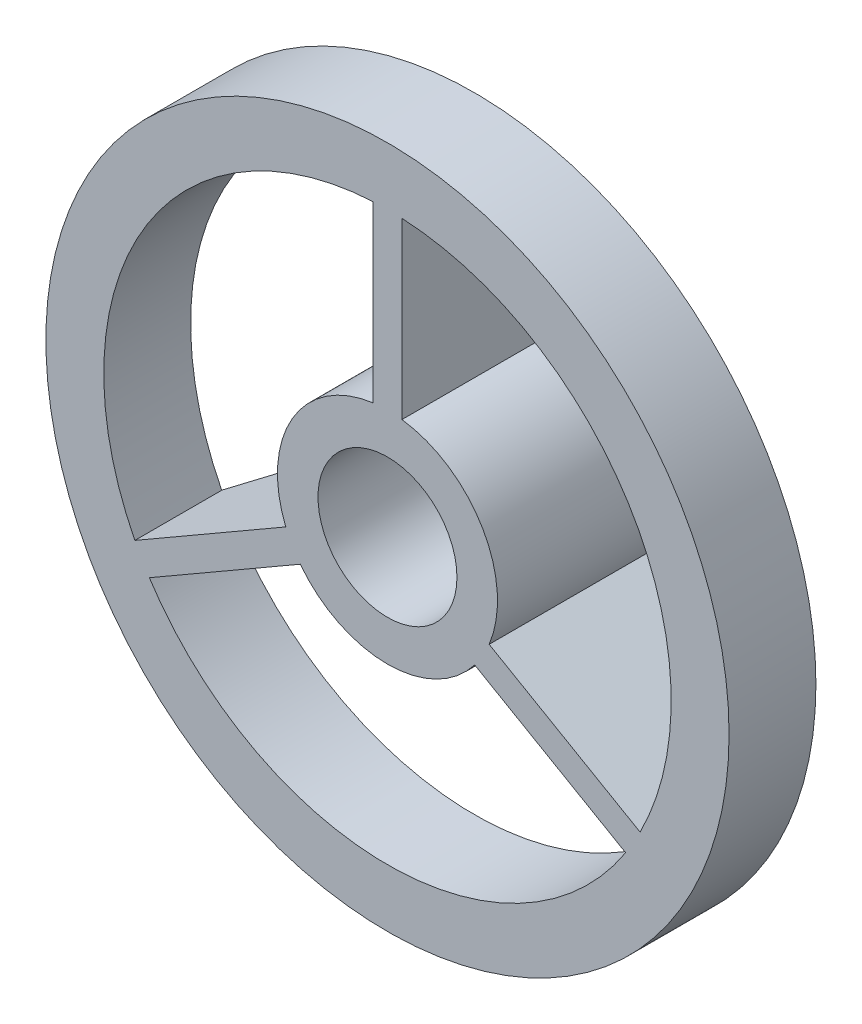
from build123d import *

# Parameters (mm, degrees)
SKETCH1_R           = 1.9
SKETCH1_R_2         = 1.2
BOSS_EXTRUDE1_DEPTH = 3.5
SKETCH2_R           = 5.9
SKETCH2_R_2         = 4.9
BOSS_EXTRUDE2_DEPTH = 1.5
BOSS_EXTRUDE7_DEPTH = 0.25
CIRPATTERN1_COUNT   = 3


with BuildPart() as part:
    # Sketch1 → Boss-Extrude1 (new body)
    with BuildSketch(Plane.XY):
        Circle(SKETCH1_R)
        Circle(SKETCH1_R_2, mode=Mode.SUBTRACT)
    extrude(amount=BOSS_EXTRUDE1_DEPTH)



with BuildPart() as body_2:
    # Sketch2 → Boss-Extrude2 (new body)
    with BuildSketch(Plane.XY.offset(3.5)):
        Circle(SKETCH2_R)
        Circle(SKETCH2_R_2, mode=Mode.SUBTRACT)
    extrude(amount=-BOSS_EXTRUDE2_DEPTH)


with BuildPart() as part_1:
    add(part.part)

    add(body_2.part)  # Boss-Extrude7 merges body 2
    # Sketch3 → Boss-Extrude7 (add, symmetric)
    with BuildSketch(Plane(origin=(0, 0, 0), x_dir=(0, 0, -1), z_dir=(1, 0, 0))):
        Polygon((-3.5, 4.9), (-2, 4.9), (0, 1.9), (0, 1.7), (-3.5, 1.7), (-3.5, 1.9), align=None)
    boss_extrude7 = extrude(amount=BOSS_EXTRUDE7_DEPTH, both=True)

    # CirPattern1: Boss-Extrude7 ×3 about axis
    cirpattern1_axis = Axis((0, 0, 0), (0, 0, 1))
    for i in range(1, CIRPATTERN1_COUNT):
        add(boss_extrude7.rotate(cirpattern1_axis, i * 360 / CIRPATTERN1_COUNT))


solid = part_1.part
